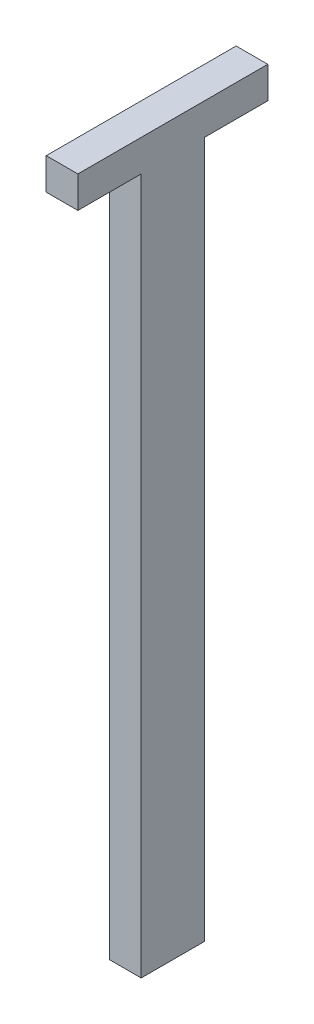
from build123d import *

# Parameters (mm, degrees)
SKETCH_1_W      = 5
SKETCH_1_H      = 10
EXTRUDE_1_DEPTH = 110
SKETCH_2_W      = 5
SKETCH_2_H      = 10
EXTRUDE_2_DEPTH = 5


with BuildPart() as part:
    # 草图1 → 凸台-拉伸1 (new body)
    with BuildSketch(Plane(origin=(0, 0, 0), x_dir=(1, 0, 0), z_dir=(0, 1, 0))):
        with Locations((2.5, 5)):
            Rectangle(SKETCH_1_W, SKETCH_1_H)
    extrude(amount=EXTRUDE_1_DEPTH)

    # 草图2 → 凸台-拉伸2 (add)
    with BuildSketch(Plane(origin=(0, 110, 0), x_dir=(1, 0, 0), z_dir=(0, 1, 0))):
        with Locations((2.5, 15)):
            Rectangle(SKETCH_2_W, SKETCH_2_H)
        with Locations((2.5, 5)):
            Rectangle(SKETCH_2_W, SKETCH_2_H)
        with Locations((2.5, -5)):
            Rectangle(SKETCH_2_W, SKETCH_2_H)
    extrude(amount=EXTRUDE_2_DEPTH)


solid = part.part
